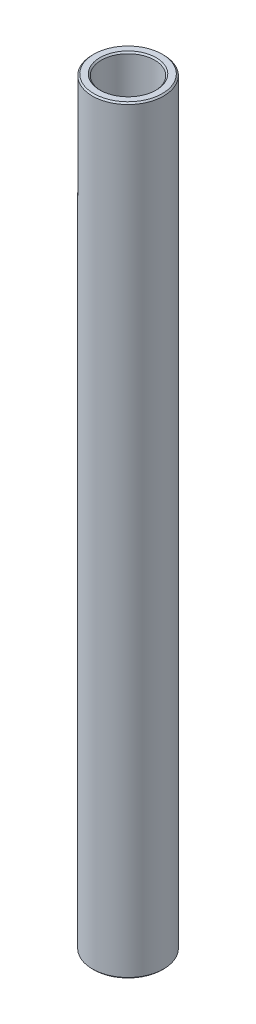
from build123d import *

# Parameters (mm, degrees)
SKETCH1_W     = 1.5875
SKETCH1_H     = 135.334375
CHAMFER1_SIZE = 0.254


with BuildPart() as part:
    # Sketch1 → Revolve1 (revolve)
    with BuildSketch(Plane.XY):
        with Locations((5.55625, 138.310882465)):
            Rectangle(SKETCH1_W, SKETCH1_H)
    revolve(axis=Axis((0, 61.118694965, 0), (0, 1, 0)))

    # Chamfer1
    chamfer1_edges = [part.edges().sort_by_distance(p)[0] for p in [
        (-6.35, 70.643694965, 0),
        (-6.35, 205.978069965, 0),
        (-4.7625, 205.978069965, 0),
        (-4.7625, 70.643694965, 0),
    ]]
    chamfer(chamfer1_edges, length=CHAMFER1_SIZE)


solid = part.part
